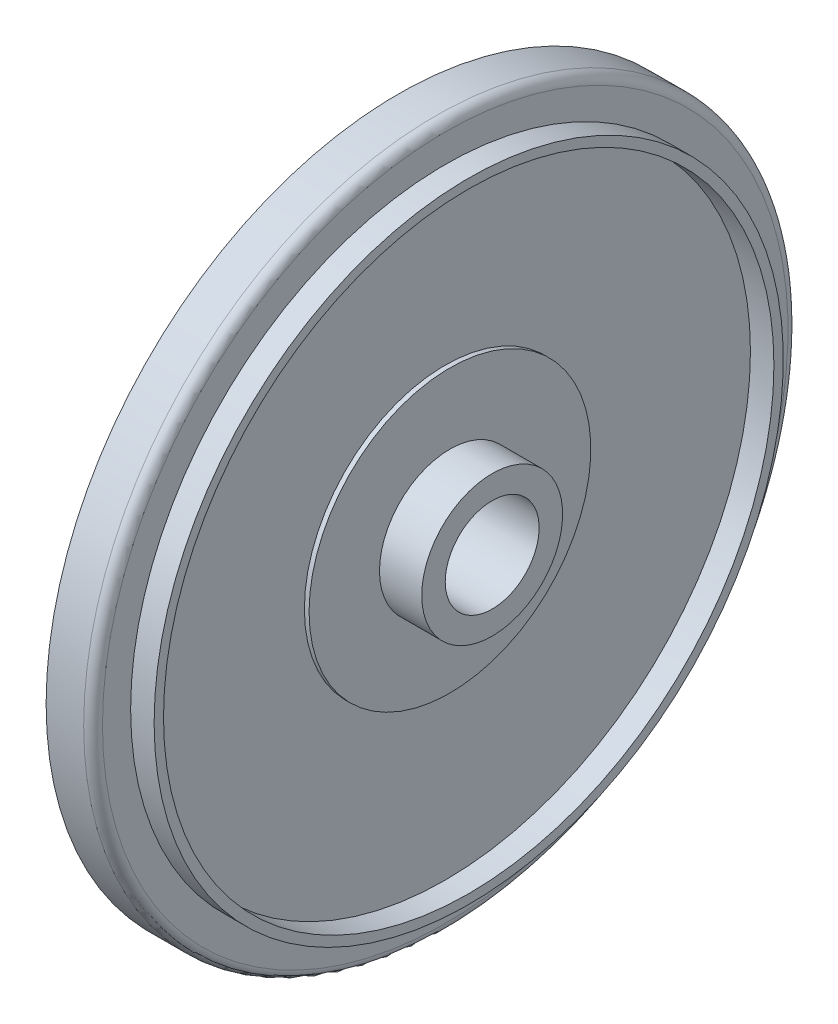
from build123d import *

# Parameters (mm, degrees)
FILLET1_R = 0.2


with BuildPart() as part:
    # Sketch1 → Revolve1 (revolve)
    with BuildSketch(Plane.XY):
        Polygon((3, 1), (3, 7.5), (4, 7.5), (4, 6.7), (4.5, 6.7), (4.5, 6.5), (4, 6.5), (4, 3), (4.1, 3), (4.1, 1.5), (5, 1.5), (5, 1), align=None)
    revolve(axis=Axis((0, 0, 0), (1, 0, 0)))

    # Fillet1
    fillet1_edges = [part.edges().sort_by_distance(p)[0] for p in [
        (4, -7.5, 0),
    ]]
    fillet(fillet1_edges, radius=FILLET1_R)


solid = part.part
